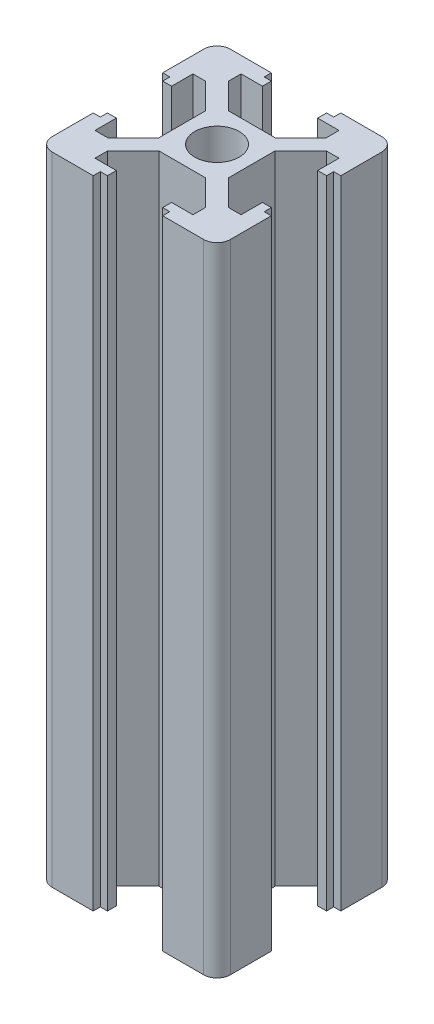
from build123d import *

# Parameters (mm, degrees)
SKETCH1_R           = 2.5
BOSS_EXTRUDE1_DEPTH = 71.5


with BuildPart() as part:
    # Sketch1 → Boss-Extrude1 (new body)
    with BuildSketch(Plane(origin=(0, 0, 0), x_dir=(1, 0, 0), z_dir=(0, 1, 0))):
        with BuildLine():
            Line((3.9, 10), (8.5, 10))
            ThreePointArc((8.5, 10), (9.560660172, 9.560660172), (10, 8.5))
            Line((10, 8.5), (10, 3.9))
            Line((10, 3.9), (9.2, 3.9))
            Line((9.2, 3.9), (9.2, 3.1))
            Line((9.2, 3.1), (8.2, 3.1))
            Line((8.2, 3.1), (8.2, 5.5))
            Line((8.2, 5.5), (6.77, 5.5))
            Line((6.77, 5.5), (3.9, 2.63))
            Line((3.9, 2.63), (3.9, 0))
            Line((3.9, 0), (3.9, -2.63))
            Line((3.9, -2.63), (6.77, -5.5))
            Line((6.77, -5.5), (8.2, -5.5))
            Line((8.2, -5.5), (8.2, -3.1))
            Line((8.2, -3.1), (9.2, -3.1))
            Line((9.2, -3.1), (9.2, -3.9))
            Line((9.2, -3.9), (10, -3.9))
            Line((10, -3.9), (10, -8.5))
            ThreePointArc((10, -8.5), (9.560660172, -9.560660172), (8.5, -10))
            Line((8.5, -10), (3.9, -10))
            Line((3.9, -10), (3.9, -9.2))
            Line((3.9, -9.2), (3.1, -9.2))
            Line((3.1, -9.2), (3.1, -8.2))
            Line((3.1, -8.2), (5.5, -8.2))
            Line((5.5, -8.2), (5.5, -6.77))
            Line((5.5, -6.77), (2.63, -3.9))
            Line((2.63, -3.9), (0, -3.9))
            Line((0, -3.9), (-2.63, -3.9))
            Line((-2.63, -3.9), (-5.5, -6.77))
            Line((-5.5, -6.77), (-5.5, -8.2))
            Line((-5.5, -8.2), (-3.1, -8.2))
            Line((-3.1, -8.2), (-3.1, -9.2))
            Line((-3.1, -9.2), (-3.9, -9.2))
            Line((-3.9, -9.2), (-3.9, -10))
            Line((-3.9, -10), (-8.5, -10))
            ThreePointArc((-8.5, -10), (-9.560660172, -9.560660172), (-10, -8.5))
            Line((-10, -8.5), (-10, -3.9))
            Line((-10, -3.9), (-9.2, -3.9))
            Line((-9.2, -3.9), (-9.2, -3.1))
            Line((-9.2, -3.1), (-8.2, -3.1))
            Line((-8.2, -3.1), (-8.2, -5.5))
            Line((-8.2, -5.5), (-6.77, -5.5))
            Line((-6.77, -5.5), (-3.9, -2.63))
            Line((-3.9, -2.63), (-3.9, 0))
            Line((-3.9, 0), (-3.9, 2.63))
            Line((-3.9, 2.63), (-6.77, 5.5))
            Line((-6.77, 5.5), (-8.2, 5.5))
            Line((-8.2, 5.5), (-8.2, 3.1))
            Line((-8.2, 3.1), (-9.2, 3.1))
            Line((-9.2, 3.1), (-9.2, 3.9))
            Line((-9.2, 3.9), (-10, 3.9))
            Line((-10, 3.9), (-10, 8.5))
            ThreePointArc((-10, 8.5), (-9.560660172, 9.560660172), (-8.5, 10))
            Line((-8.5, 10), (-3.9, 10))
            Line((-3.9, 10), (-3.9, 9.2))
            Line((-3.9, 9.2), (-3.1, 9.2))
            Line((-3.1, 9.2), (-3.1, 8.2))
            Line((-3.1, 8.2), (-5.5, 8.2))
            Line((-5.5, 8.2), (-5.5, 6.77))
            Line((-5.5, 6.77), (-2.63, 3.9))
            Line((-2.63, 3.9), (2.63, 3.9))
            Line((2.63, 3.9), (5.5, 6.77))
            Line((5.5, 6.77), (5.5, 8.2))
            Line((5.5, 8.2), (3.1, 8.2))
            Line((3.1, 8.2), (3.1, 9.2))
            Line((3.1, 9.2), (3.9, 9.2))
            Line((3.9, 9.2), (3.9, 10))
        make_face()
        Circle(SKETCH1_R, mode=Mode.SUBTRACT)
    extrude(amount=BOSS_EXTRUDE1_DEPTH)


solid = part.part
